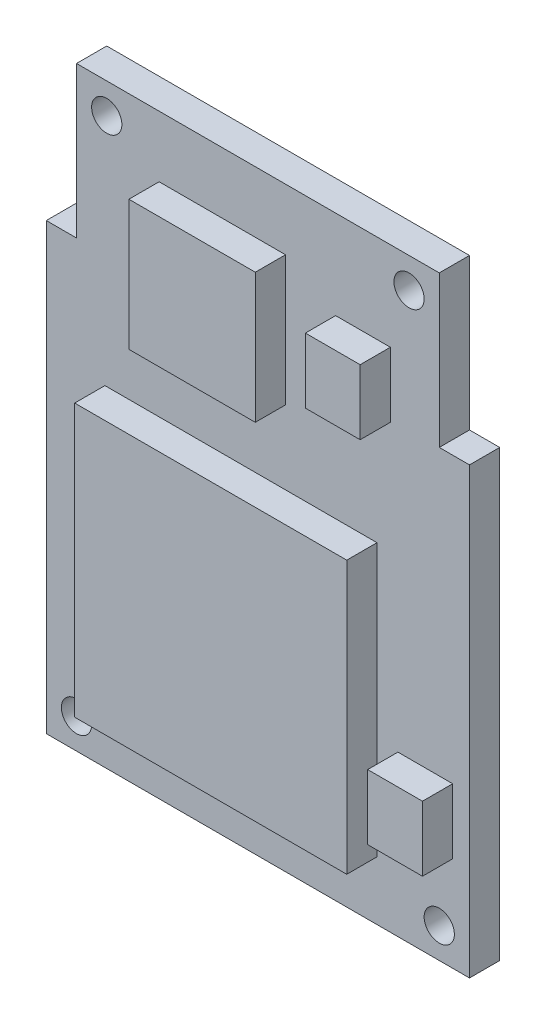
from build123d import *

# Parameters (mm, degrees)
SKETCH_1_W          = 14
SKETCH_1_H          = 14.7
EXTRUDE_1_DEPTH     = 1
SKETCH_2_W          = 12
SKETCH_2_H          = 5
EXTRUDE_2_DEPTH     = 1
SKETCH_3_R          = 0.5
CUT_EXTRUDE_1_DEPTH = 2
SKETCH_4_W          = 4.181251824
SKETCH_4_H          = 4.30078239
SKETCH_4_W_2        = 9
SKETCH_4_H_2        = 9
SKETCH_4_W_3        = 1.811721258
SKETCH_4_H_3        = 2.150391195
EXTRUDE_3_DEPTH     = 1
SKETCH_5_W          = 1.98908545
SKETCH_5_H          = 7.5
SKETCH_5_W_2        = 2.470298365
SKETCH_5_H_2        = 2.390611322
EXTRUDE_4_DEPTH     = 1


with BuildPart() as part:
    # 草图1 → 凸台-拉伸1 (new body)
    with BuildSketch(Plane.XY):
        Rectangle(SKETCH_1_W, SKETCH_1_H)
    extrude(amount=EXTRUDE_1_DEPTH)

    # 草图2 → 凸台-拉伸2 (add)
    with BuildSketch(Plane.XY):
        with Locations((0, 9.85)):
            Rectangle(SKETCH_2_W, SKETCH_2_H)
    extrude(amount=EXTRUDE_2_DEPTH)

    # 草图3 → 切除-拉伸1 (cut, through all)
    with BuildSketch(Plane.XY.offset(1)):
        with Locations((-5, 11.35)):
            Circle(SKETCH_3_R)
        with Locations((5, 11.35)):
            Circle(SKETCH_3_R)
        with Locations((-6, -6.35)):
            Circle(SKETCH_3_R)
        with Locations((6, -6.35)):
            Circle(SKETCH_3_R)
    extrude(amount=-CUT_EXTRUDE_1_DEPTH, mode=Mode.SUBTRACT)

    # 草图4 → 凸台-拉伸3 (add)
    with BuildSketch(Plane.XY.offset(1)):
        with Locations((-1.176542894, 8.176542894)):
            Rectangle(SKETCH_4_W, SKETCH_4_H)
        with Locations((-0.560127297, -0.908939121)):
            Rectangle(SKETCH_4_W_2, SKETCH_4_H_2)
        with Locations((3.476926793, 8.336496479)):
            Rectangle(SKETCH_4_W_3, SKETCH_4_H_3)
        with Locations((5.538249561, -3.137858366)):
            Rectangle(SKETCH_4_W_3, SKETCH_4_H_3)
    extrude(amount=EXTRUDE_3_DEPTH)

    # 草图5 → 凸台-拉伸4 (add)
    with BuildSketch(Plane(origin=(0, 0, 0), x_dir=(-1, 0, 0), z_dir=(0, 0, -1))):
        with Locations((5.005457275, -0.6)):
            Rectangle(SKETCH_5_W, SKETCH_5_H)
        with Locations((-2.94842063, 6.623804529)):
            Rectangle(SKETCH_5_W_2, SKETCH_5_H_2)
    extrude(amount=EXTRUDE_4_DEPTH)


solid = part.part
